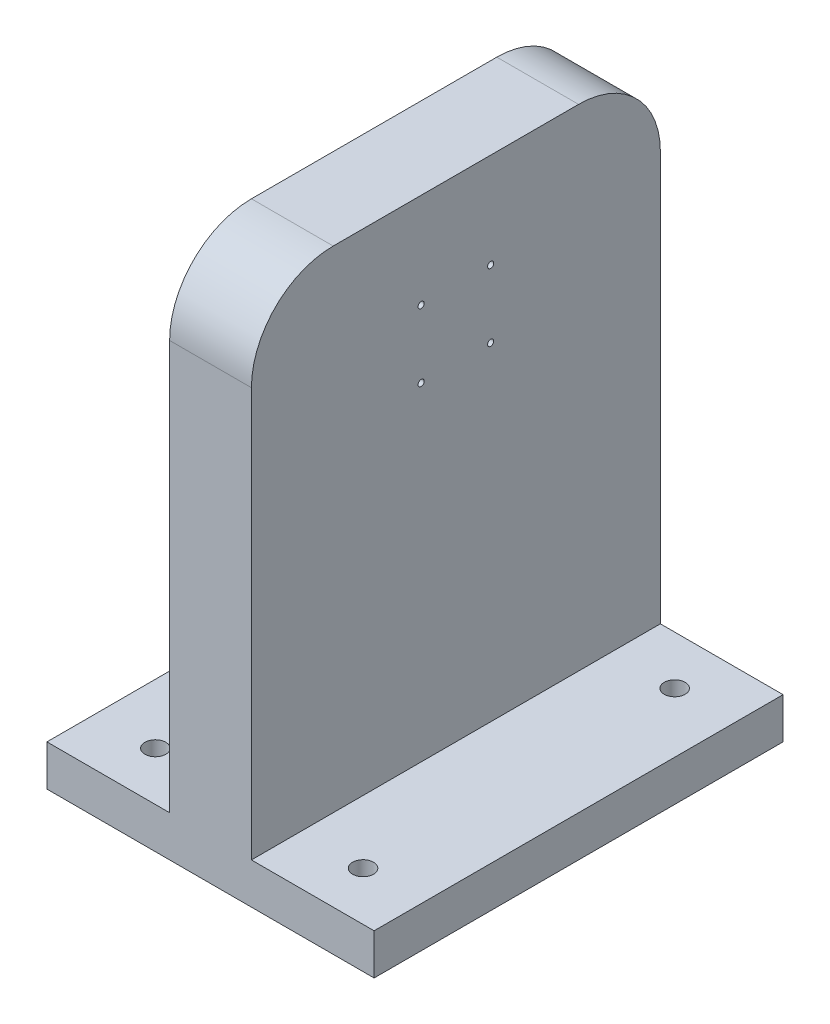
from build123d import *

# Parameters (mm, degrees)
SKETCH2_W           = 80
SKETCH2_H           = 100
BOSS_EXTRUDE1_DEPTH = 10
SKETCH3_W           = 20
SKETCH3_H           = 100
BOSS_EXTRUDE2_DEPTH = 120
SKETCH5_R           = 2.555
CUT_EXTRUDE2_DEPTH  = 55
FILLET2_R           = 20
SKETCH4_R           = 0.75
CUT_EXTRUDE3_DEPTH  = 51


with BuildPart() as part:
    # Sketch2 → Boss-Extrude1 (new body)
    with BuildSketch(Plane(origin=(0, 0, 0), x_dir=(1, 0, 0), z_dir=(0, 1, 0))):
        Rectangle(SKETCH2_W, SKETCH2_H)
    extrude(amount=BOSS_EXTRUDE1_DEPTH)

    # Sketch3 → Boss-Extrude2 (add)
    with BuildSketch(Plane(origin=(0, 10, 0), x_dir=(1, 0, 0), z_dir=(0, 1, 0))):
        Rectangle(SKETCH3_W, SKETCH3_H)
    extrude(amount=BOSS_EXTRUDE2_DEPTH)

    # Sketch5 → Cut-Extrude2 (cut)
    with BuildSketch(Plane.XZ):
        with Locations((-25.4, -38.1)):
            Circle(SKETCH5_R)
        with Locations((25.4, -38.1)):
            Circle(SKETCH5_R)
        with Locations((-25.4, 38.1)):
            Circle(SKETCH5_R)
        with Locations((25.4, 38.1)):
            Circle(SKETCH5_R)
    extrude(amount=-CUT_EXTRUDE2_DEPTH, mode=Mode.SUBTRACT)

    # Fillet2
    fillet2_edges = [part.edges().sort_by_distance(p)[0] for p in [
        (0, 130, -50),
        (0, 130, 50),
    ]]
    fillet(fillet2_edges, radius=FILLET2_R)

    # Sketch4 → Cut-Extrude3 (cut, through all)
    with BuildSketch(Plane.ZY.offset(10)):
        with Locations((-8.5, 106.75)):
            Circle(SKETCH4_R)
        with Locations((-8.5, 90.25)):
            Circle(SKETCH4_R)
        with Locations((8.5, 90.25)):
            Circle(SKETCH4_R)
        with Locations((8.5, 106.75)):
            Circle(SKETCH4_R)
    extrude(amount=-CUT_EXTRUDE3_DEPTH, mode=Mode.SUBTRACT)


solid = part.part
